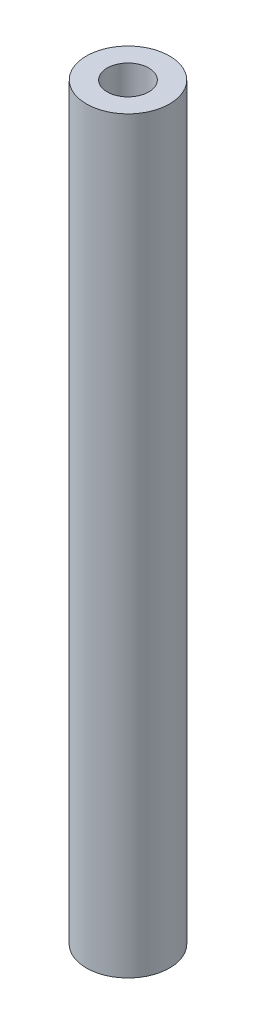
from build123d import *

# Parameters (mm, degrees)
SKETCH1_R           = 5
SKETCH1_R_2         = 2.5
BOSS_EXTRUDE1_DEPTH = 90


with BuildPart() as part:
    # Sketch1 → Boss-Extrude1 (new body)
    with BuildSketch(Plane(origin=(0, 0, 0), x_dir=(1, 0, 0), z_dir=(0, 1, 0))):
        Circle(SKETCH1_R)
        Circle(SKETCH1_R_2, mode=Mode.SUBTRACT)
    extrude(amount=BOSS_EXTRUDE1_DEPTH)


solid = part.part
